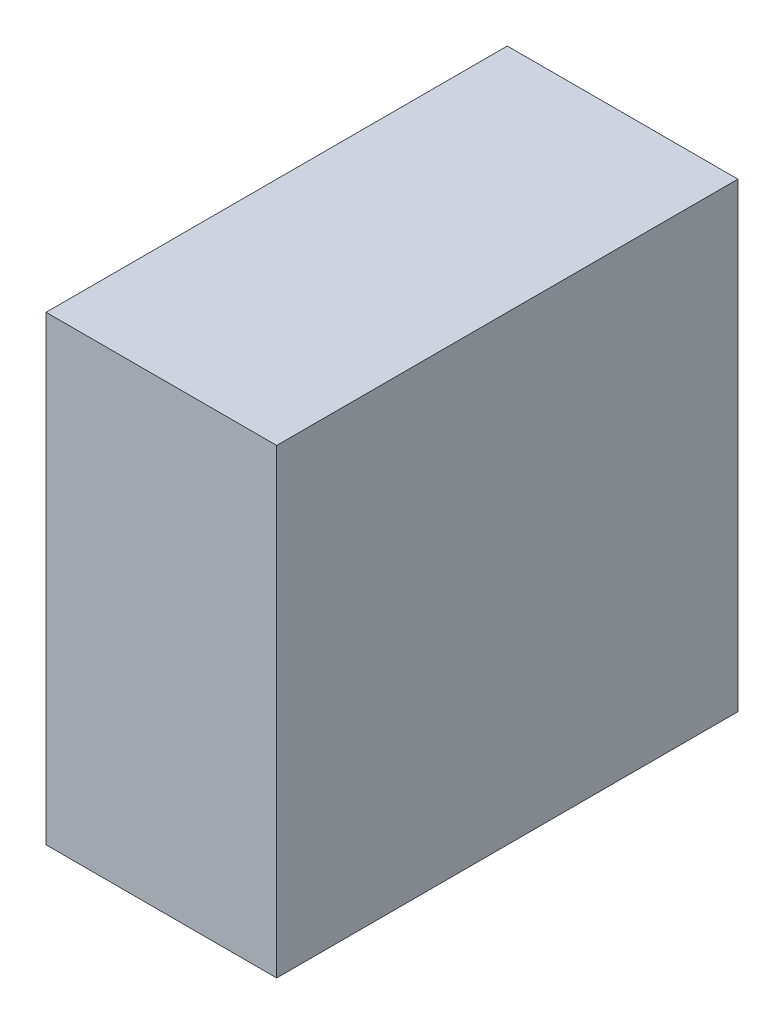
from build123d import *

# Parameters (mm, degrees)
SKETCH1_W           = 40
SKETCH1_H           = 40
BOSS_EXTRUDE1_DEPTH = 40
CUT_EXTRUDE1_DEPTH  = 40
CUT_EXTRUDE2_DEPTH  = 20


with BuildPart() as part:
    # Sketch1 → Boss-Extrude1 (new body)
    with BuildSketch(Plane.XY):
        with Locations((20, 20)):
            Rectangle(SKETCH1_W, SKETCH1_H)
    extrude(amount=BOSS_EXTRUDE1_DEPTH)

    # Sketch2 → Cut-Extrude1 (cut)
    with BuildSketch(Plane.XY.offset(40)):
        Polygon((0, 0), (20, 40), (0, 40), align=None)
    extrude(amount=-CUT_EXTRUDE1_DEPTH, mode=Mode.SUBTRACT)

    # Sketch3 → Cut-Extrude2 (cut)
    with BuildSketch(Plane.XY.offset(40)):
        Polygon((20, 40), (20, 0), (0, 0), align=None)
    extrude(amount=-CUT_EXTRUDE2_DEPTH, mode=Mode.SUBTRACT)


solid = part.part
